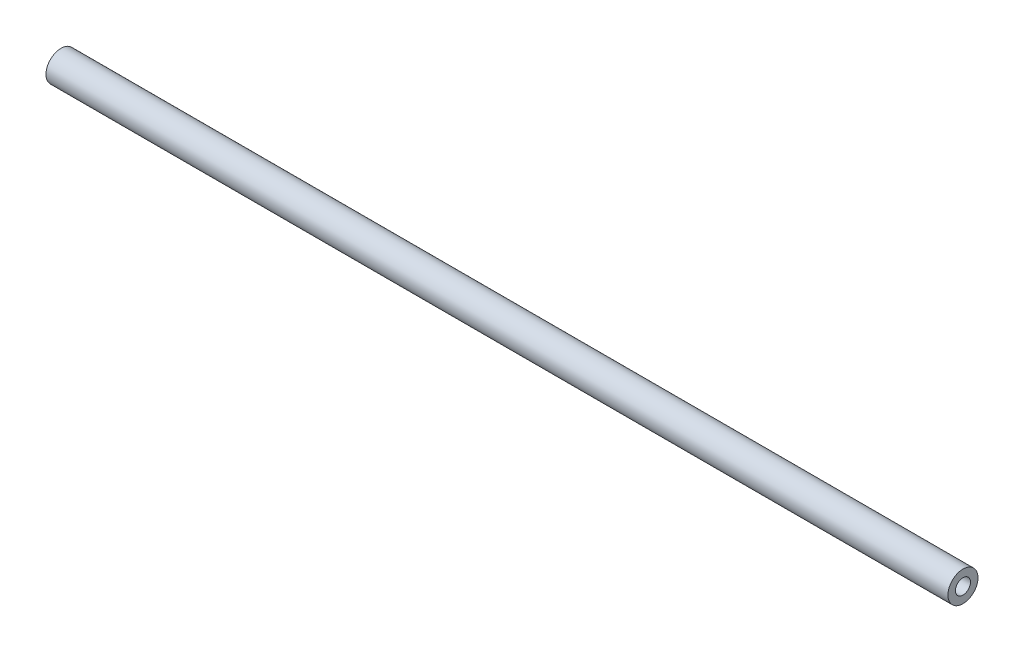
from build123d import *

# Parameters (mm, degrees)
SKETCH1_R           = 6.35
BOSS_EXTRUDE1_DEPTH = 381
SKETCH2_R           = 3.175
CUT_EXTRUDE1_DEPTH  = 382


with BuildPart() as part:
    # Sketch1 → Boss-Extrude1 (new body)
    with BuildSketch(Plane(origin=(0, 0, 0), x_dir=(0, 0, -1), z_dir=(1, 0, 0))):
        Circle(SKETCH1_R)
    extrude(amount=BOSS_EXTRUDE1_DEPTH)

    # Sketch2 → Cut-Extrude1 (cut, through all)
    with BuildSketch(Plane(origin=(381, 0, 0), x_dir=(0, 0, -1), z_dir=(1, 0, 0))):
        Circle(SKETCH2_R)
    extrude(amount=-CUT_EXTRUDE1_DEPTH, mode=Mode.SUBTRACT)


solid = part.part
